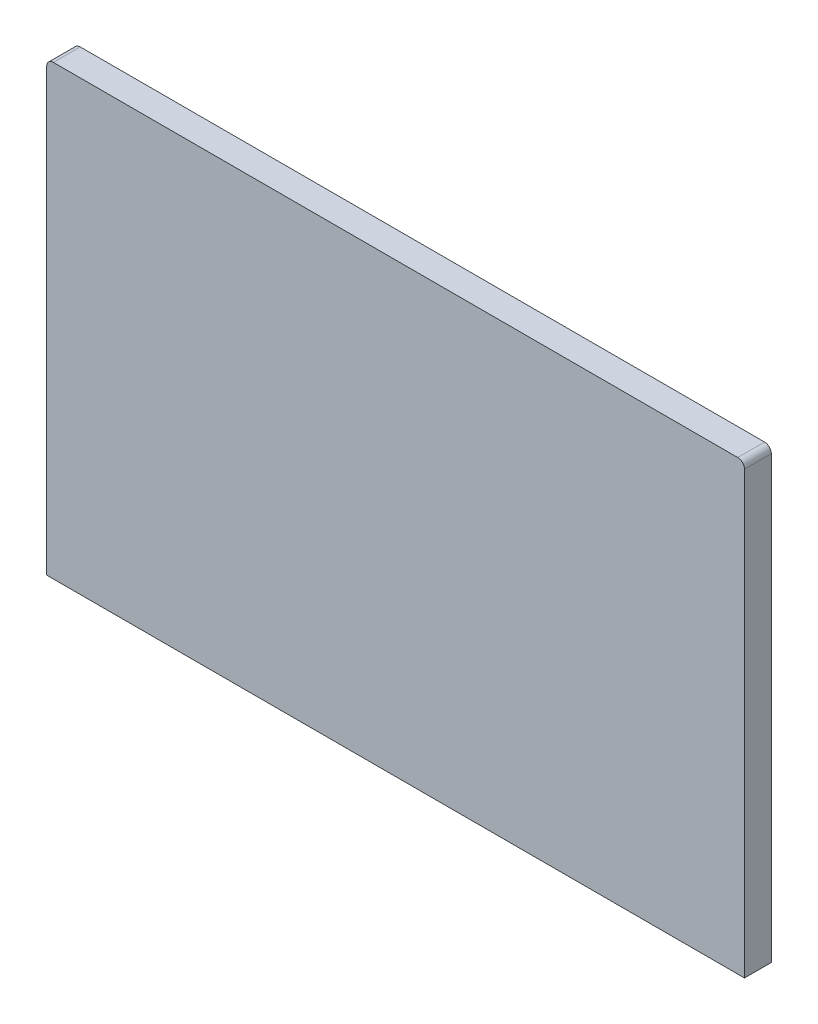
from build123d import *

# Parameters (mm, degrees)
BOSS_EXTRUDE1_DEPTH = 2


with BuildPart() as part:
    # Sketch1 → Boss-Extrude1 (new body)
    with BuildSketch(Plane.XY):
        with BuildLine():
            Line((26, 13.571107206), (26, 17.571107206))
            ThreePointArc((26, 17.571107206), (25.853553391, 17.924660596), (25.5, 18.071107206))
            Line((25.5, 18.071107206), (21.499997229, 18.071107206))
            Line((21.499997229, 18.071107206), (21, 18.071107206))
            Line((21, 18.071107206), (-21, 18.071107206))
            Line((-21, 18.071107206), (-21.5, 18.071107206))
            Line((-21.5, 18.071107206), (-25.5, 18.071107206))
            ThreePointArc((-25.5, 18.071107206), (-25.853553391, 17.924660596), (-26, 17.571107206))
            Line((-26, 17.571107206), (-26, 13.571104435))
            Line((-26, 13.571104435), (-26, 13.071107206))
            Line((-26, 13.071107206), (-26, -15.268618748))
            Line((-26, -15.268618748), (26, -15.268618748))
            Line((26, -15.268618748), (26, 13.071107206))
            Line((26, 13.071107206), (26, 13.571107206))
        make_face()
    extrude(amount=BOSS_EXTRUDE1_DEPTH)


solid = part.part
